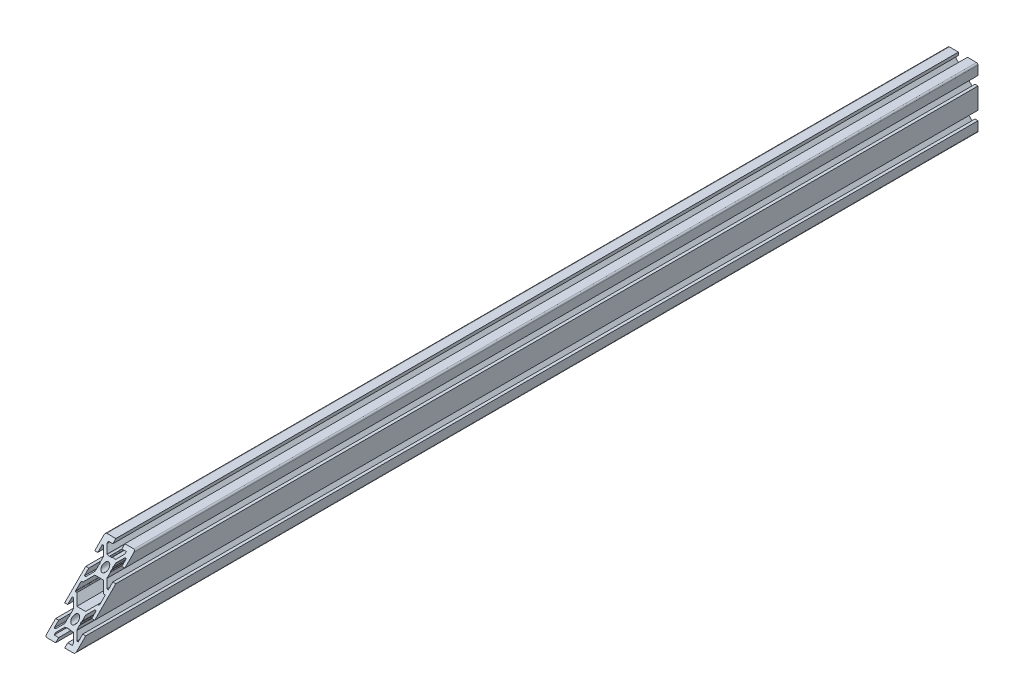
from build123d import *

# Parameters (mm, degrees)
SKETCH1_R           = 2.1
BOSS_EXTRUDE1_DEPTH = 600
CUT_EXTRUDE2_DEPTH  = 21
SKETCH4_R           = 2
CUT_EXTRUDE3_DEPTH  = 21


with BuildPart() as part:
    # Sketch1 → Boss-Extrude1 (new body)
    with BuildSketch(Plane(origin=(0, 0, -600), x_dir=(-1, 0, 0), z_dir=(0, 0, -1))):
        with BuildLine():
            Line((10, -7), (10, 7))
            Line((10, 7), (8, 7))
            Line((8, 7), (8, 4))
            Line((8, 4), (7.060660172, 4))
            Line((7.060660172, 4), (4, 7.060660172))
            Line((4, 7.060660172), (4, 7.5))
            Line((4, 7.5), (3.750976592, 8.781114371))
            Line((3.750976592, 8.781114371), (3.933012702, 9.096410162))
            ThreePointArc((3.933012702, 9.096410162), (4, 9.346410162), (3.933012702, 9.596410162))
            Line((3.933012702, 9.596410162), (3.7, 10))
            Line((3.7, 10), (3.933012702, 10.403589838))
            ThreePointArc((3.933012702, 10.403589838), (3.982962913, 10.524180316), (4, 10.653589838))
            Line((4, 10.653589838), (4, 12.939339828))
            Line((4, 12.939339828), (7.060660172, 16))
            Line((7.060660172, 16), (8, 16))
            Line((8, 16), (8, 13))
            Line((8, 13), (10, 13))
            Line((10, 13), (10, 19))
            ThreePointArc((10, 19), (9.707106781, 19.707106781), (9, 20))
            Line((9, 20), (3, 20))
            Line((3, 20), (3, 18))
            Line((3, 18), (6, 18))
            Line((6, 18), (6, 17.060660172))
            Line((6, 17.060660172), (2.939339828, 14))
            Line((2.939339828, 14), (2.5, 14))
            Line((2.5, 14), (1.218885629, 13.750976592))
            Line((1.218885629, 13.750976592), (0.903589838, 13.933012702))
            ThreePointArc((0.903589838, 13.933012702), (0.653589838, 14), (0.403589838, 13.933012702))
            Line((0.403589838, 13.933012702), (0, 13.7))
            Line((0, 13.7), (-0.403589838, 13.933012702))
            ThreePointArc((-0.403589838, 13.933012702), (-0.524180316, 13.982962913), (-0.653589838, 14))
            Line((-0.653589838, 14), (-2.939339828, 14))
            Line((-2.939339828, 14), (-6, 17.060660172))
            Line((-6, 17.060660172), (-6, 18))
            Line((-6, 18), (-3, 18))
            Line((-3, 18), (-3, 20))
            Line((-3, 20), (-9, 20))
            ThreePointArc((-9, 20), (-9.707106781, 19.707106781), (-10, 19))
            Line((-10, 19), (-10, 13))
            Line((-10, 13), (-8, 13))
            Line((-8, 13), (-8, 16))
            Line((-8, 16), (-7.060660172, 16))
            Line((-7.060660172, 16), (-4, 12.939339828))
            Line((-4, 12.939339828), (-4, 12.5))
            Line((-4, 12.5), (-3.750976592, 11.218885629))
            Line((-3.750976592, 11.218885629), (-3.933012702, 10.903589838))
            ThreePointArc((-3.933012702, 10.903589838), (-4, 10.653589838), (-3.933012702, 10.403589838))
            Line((-3.933012702, 10.403589838), (-3.7, 10))
            Line((-3.7, 10), (-3.933012702, 9.596410162))
            ThreePointArc((-3.933012702, 9.596410162), (-3.982962913, 9.475819684), (-4, 9.346410162))
            Line((-4, 9.346410162), (-4, 7.060660172))
            Line((-4, 7.060660172), (-7.060660172, 4))
            Line((-7.060660172, 4), (-8, 4))
            Line((-8, 4), (-8, 7))
            Line((-8, 7), (-10, 7))
            Line((-10, 7), (-10, -7))
            Line((-10, -7), (-8, -7))
            Line((-8, -7), (-8, -4))
            Line((-8, -4), (-7.060660172, -4))
            Line((-7.060660172, -4), (-4, -7.060660172))
            Line((-4, -7.060660172), (-4, -9.346410162))
            ThreePointArc((-4, -9.346410162), (-3.982962913, -9.475819684), (-3.933012702, -9.596410162))
            Line((-3.933012702, -9.596410162), (-3.7, -10))
            Line((-3.7, -10), (-3.933012702, -10.403589838))
            ThreePointArc((-3.933012702, -10.403589838), (-4, -10.653589838), (-3.933012702, -10.903589838))
            Line((-3.933012702, -10.903589838), (-3.750976592, -11.218885629))
            Line((-3.750976592, -11.218885629), (-4, -12.5))
            Line((-4, -12.5), (-4, -12.939339828))
            Line((-4, -12.939339828), (-7.060660172, -16))
            Line((-7.060660172, -16), (-8, -16))
            Line((-8, -16), (-8, -13))
            Line((-8, -13), (-10, -13))
            Line((-10, -13), (-10, -19))
            ThreePointArc((-10, -19), (-9.707106781, -19.707106781), (-9, -20))
            Line((-9, -20), (-3, -20))
            Line((-3, -20), (-3, -18))
            Line((-3, -18), (-6, -18))
            Line((-6, -18), (-6, -17.060660172))
            Line((-6, -17.060660172), (-2.939339828, -14))
            Line((-2.939339828, -14), (-0.653589838, -14))
            ThreePointArc((-0.653589838, -14), (-0.524180316, -13.982962913), (-0.403589838, -13.933012702))
            Line((-0.403589838, -13.933012702), (0, -13.7))
            Line((0, -13.7), (0.403589839, -13.933012702))
            ThreePointArc((0.403589839, -13.933012702), (0.653589839, -14), (0.903589838, -13.933012702))
            Line((0.903589838, -13.933012702), (1.218885629, -13.750976592))
            Line((1.218885629, -13.750976592), (2.5, -14))
            Line((2.5, -14), (2.939339828, -14))
            Line((2.939339828, -14), (6, -17.060660172))
            Line((6, -17.060660172), (6, -18))
            Line((6, -18), (3, -18))
            Line((3, -18), (3, -20))
            Line((3, -20), (9, -20))
            ThreePointArc((9, -20), (9.707106781, -19.707106781), (10, -19))
            Line((10, -19), (10, -13))
            Line((10, -13), (8, -13))
            Line((8, -13), (8, -16))
            Line((8, -16), (7.060660172, -16))
            Line((7.060660172, -16), (4, -12.939339828))
            Line((4, -12.939339828), (4, -10.653589838))
            ThreePointArc((4, -10.653589838), (3.982962913, -10.524180316), (3.933012702, -10.403589838))
            Line((3.933012702, -10.403589838), (3.7, -10))
            Line((3.7, -10), (3.933012702, -9.596410162))
            ThreePointArc((3.933012702, -9.596410162), (4, -9.346410162), (3.933012702, -9.096410162))
            Line((3.933012702, -9.096410162), (3.750976592, -8.781114371))
            Line((3.750976592, -8.781114371), (4, -7.5))
            Line((4, -7.5), (4, -7.060660172))
            Line((4, -7.060660172), (7.060660172, -4))
            Line((7.060660172, -4), (8, -4))
            Line((8, -4), (8, -7))
            Line((8, -7), (10, -7))
        make_face()
        with Locations((0, -10)):
            Circle(SKETCH1_R, mode=Mode.SUBTRACT)
        with Locations((0, 10)):
            Circle(SKETCH1_R, mode=Mode.SUBTRACT)
        with BuildLine():
            Line((8, 1.7), (8, -1.7))
            ThreePointArc((8, -1.7), (7.912132034, -1.912132034), (7.7, -2))
            Line((7.7, -2), (7.063603897, -2))
            ThreePointArc((7.063603897, -2), (6.948798867, -2.02283614), (6.851471863, -2.087867966))
            Line((6.851471863, -2.087867966), (2.939339828, -6))
            Line((2.939339828, -6), (-2.939339828, -6))
            Line((-2.939339828, -6), (-6.851471863, -2.087867966))
            ThreePointArc((-6.851471863, -2.087867966), (-6.948798867, -2.02283614), (-7.063603897, -2))
            Line((-7.063603897, -2), (-7.7, -2))
            ThreePointArc((-7.7, -2), (-7.912132034, -1.912132034), (-8, -1.7))
            Line((-8, -1.7), (-8, 1.7))
            ThreePointArc((-8, 1.7), (-7.912132034, 1.912132034), (-7.7, 2))
            Line((-7.7, 2), (-7.063603897, 2))
            ThreePointArc((-7.063603897, 2), (-6.948798867, 2.02283614), (-6.851471863, 2.087867966))
            Line((-6.851471863, 2.087867966), (-2.939339828, 6))
            Line((-2.939339828, 6), (2.939339828, 6))
            Line((2.939339828, 6), (6.851471863, 2.087867966))
            ThreePointArc((6.851471863, 2.087867966), (6.948798867, 2.02283614), (7.063603897, 2))
            Line((7.063603897, 2), (7.7, 2))
            ThreePointArc((7.7, 2), (7.912132034, 1.912132034), (8, 1.7))
        make_face(mode=Mode.SUBTRACT)
    extrude(amount=-BOSS_EXTRUDE1_DEPTH)

    # Sketch3 → Cut-Extrude2 (cut, through all)
    with BuildSketch(Plane(origin=(10, 0, 0), x_dir=(0, 0, -1), z_dir=(1, 0, 0))):
        Polygon((0, -20), (40, 20), (0, 20), align=None)
    extrude(amount=-CUT_EXTRUDE2_DEPTH, mode=Mode.SUBTRACT)

    # Sketch4 → Cut-Extrude3 (cut, through all)
    with BuildSketch(Plane(origin=(10, 0, 0), x_dir=(0, 0, -1), z_dir=(1, 0, 0))):
        with Locations((590, 10)):
            Circle(SKETCH4_R)
        with Locations((590, -10)):
            Circle(SKETCH4_R)
    extrude(amount=-CUT_EXTRUDE3_DEPTH, mode=Mode.SUBTRACT)


solid = part.part
